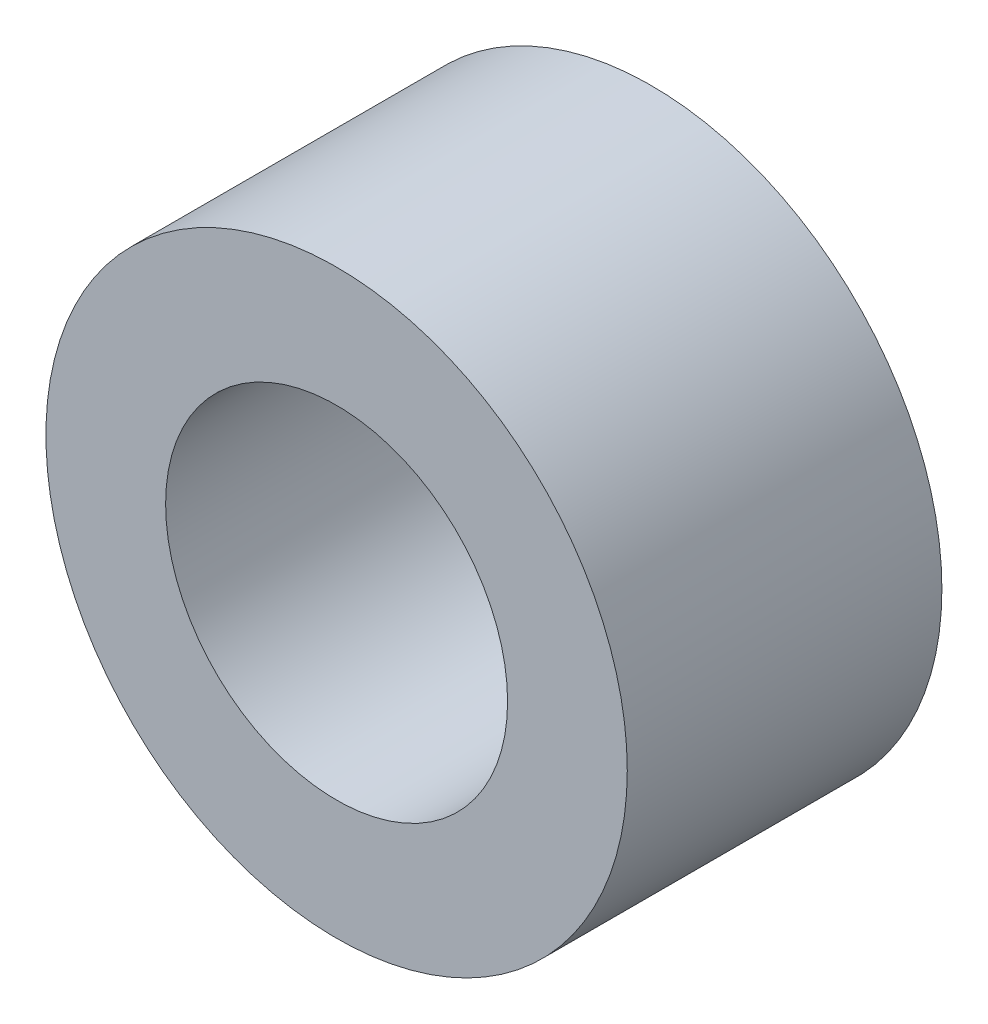
from build123d import *

# Parameters (mm, degrees)
SKETCH_3_R          = 8.5
EXTRUDE_2_DEPTH     = 4.6
SKETCH_4_R          = 5
CUT_EXTRUDE_1_DEPTH = 4.6


with BuildPart() as part:
    # 草图3 → 凸台-拉伸2 (new body, symmetric)
    with BuildSketch(Plane.XY):
        Circle(SKETCH_3_R)
    extrude(amount=EXTRUDE_2_DEPTH, both=True)

    # 草图4 → 切除-拉伸1 (cut, symmetric)
    with BuildSketch(Plane.XY):
        Circle(SKETCH_4_R)
    extrude(amount=CUT_EXTRUDE_1_DEPTH, both=True, mode=Mode.SUBTRACT)


solid = part.part
